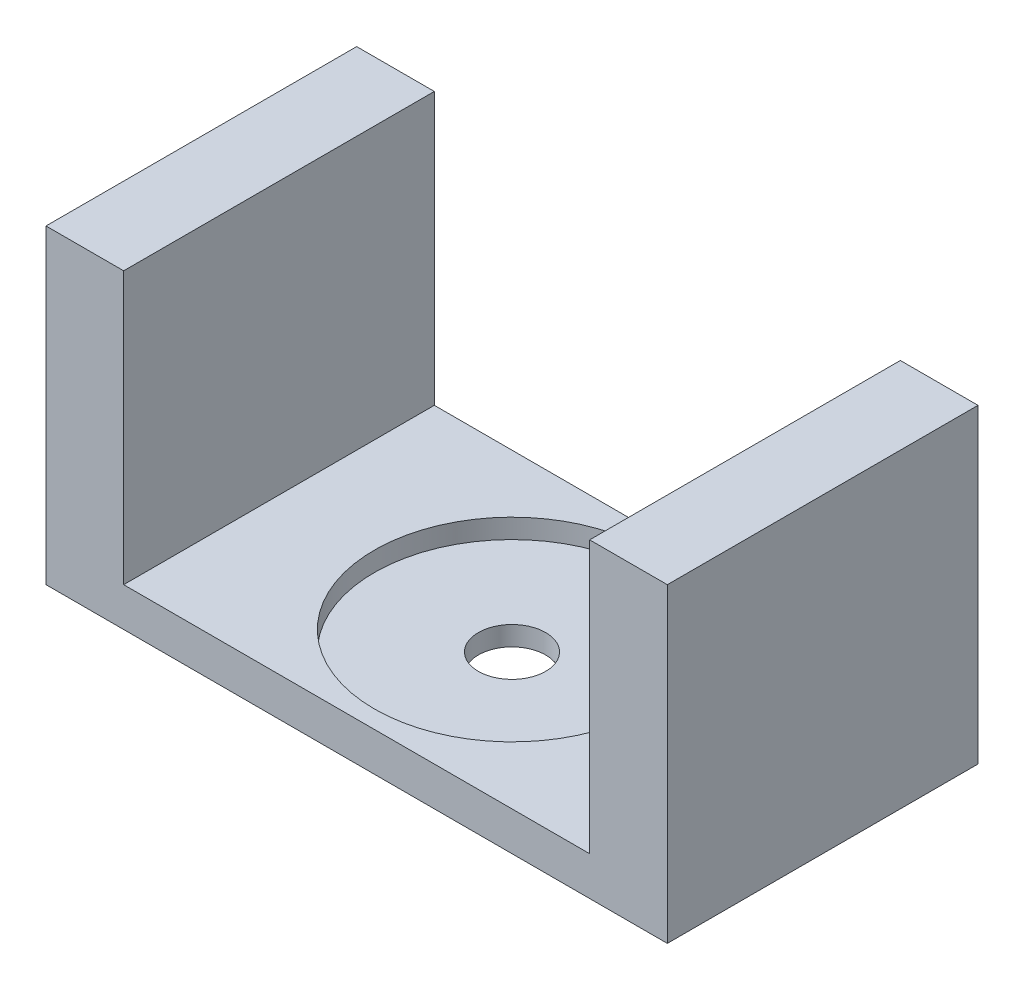
from build123d import *

# Parameters (mm, degrees)
BOSS_EXTRUDE1_DEPTH = 50.8
SKETCH2_R           = 22.5044
CUT_EXTRUDE1_DEPTH  = 3.175
SKETCH3_R           = 5.5
CUT_EXTRUDE2_DEPTH  = 4.175


with BuildPart() as part:
    # Sketch1 → Boss-Extrude1 (new body)
    with BuildSketch(Plane.XY):
        Polygon((50.8, 0), (-50.8, 0), (-50.8, 50.8), (-38.1, 50.8), (-38.1, 6.35), (38.1, 6.35), (38.1, 50.8), (50.8, 50.8), align=None)
    extrude(amount=BOSS_EXTRUDE1_DEPTH)

    # Sketch2 → Cut-Extrude1 (cut)
    with BuildSketch(Plane(origin=(0, 6.35, 0), x_dir=(1, 0, 0), z_dir=(0, 1, 0))):
        with Locations((0, -25.4)):
            Circle(SKETCH2_R)
    extrude(amount=-CUT_EXTRUDE1_DEPTH, mode=Mode.SUBTRACT)

    # Sketch3 → Cut-Extrude2 (cut, through all)
    with BuildSketch(Plane(origin=(0, 3.175, 0), x_dir=(1, 0, 0), z_dir=(0, 1, 0))):
        with Locations((0, -25.4)):
            Circle(SKETCH3_R)
    extrude(amount=-CUT_EXTRUDE2_DEPTH, mode=Mode.SUBTRACT)


solid = part.part
